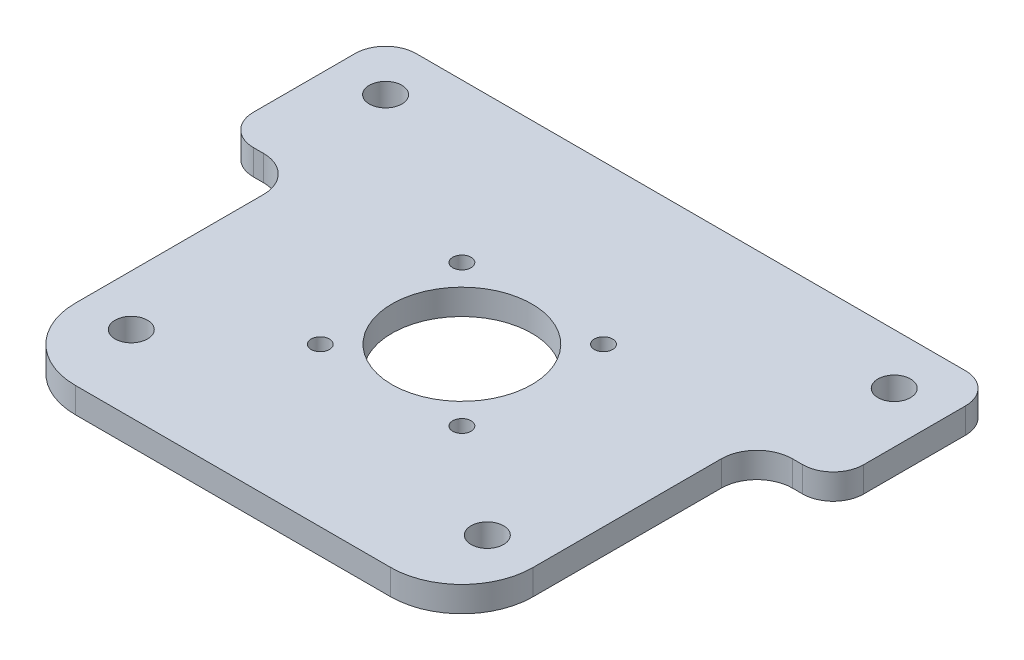
from build123d import *

# Parameters (mm, degrees)
SKETCH1_W           = 114.3
SKETCH1_H           = 114.3
BOSS_EXTRUDE1_DEPTH = 6.35
SKETCH3_W           = 19.05
SKETCH3_H           = 40.64
BOSS_EXTRUDE2_DEPTH = 6.35
SKETCH2_R           = 4.064
SKETCH2_R_2         = 17.4625
SKETCH2_R_3         = 2.286
CUT_EXTRUDE1_DEPTH  = 7.35
FILLET1_R           = 8.89
FILLET2_R           = 17.78
FILLET3_R           = 7.62


with BuildPart() as part:
    # Sketch1 → Boss-Extrude1 (new body)
    with BuildSketch(Plane(origin=(0, 0, 0), x_dir=(1, 0, 0), z_dir=(0, 1, 0))):
        Rectangle(SKETCH1_W, SKETCH1_H)
    extrude(amount=BOSS_EXTRUDE1_DEPTH)

    # Sketch3 → Boss-Extrude2 (add)
    with BuildSketch(Plane(origin=(0, 6.35, 0), x_dir=(1, 0, 0), z_dir=(0, 1, 0))):
        with Locations((66.675, 36.83)):
            Rectangle(SKETCH3_W, SKETCH3_H)
        with Locations((-66.675, 36.83)):
            Rectangle(SKETCH3_W, SKETCH3_H)
    extrude(amount=-BOSS_EXTRUDE2_DEPTH)

    # Sketch2 → Cut-Extrude1 (cut, through all)
    with BuildSketch(Plane(origin=(0, 6.35, 0), x_dir=(1, 0, 0), z_dir=(0, 1, 0))):
        with Locations((-63.5, 44.45)):
            Circle(SKETCH2_R)
        with Locations((63.5, 44.45)):
            Circle(SKETCH2_R)
        with Locations((44.45, -38.1)):
            Circle(SKETCH2_R)
        with Locations((-44.45, -38.1)):
            Circle(SKETCH2_R)
        Circle(SKETCH2_R_2)
        with Locations((-17.67766953, 17.67766953)):
            Circle(SKETCH2_R_3)
        with Locations((17.67766953, 17.67766953)):
            Circle(SKETCH2_R_3)
        with Locations((17.67766953, -17.67766953)):
            Circle(SKETCH2_R_3)
        with Locations((-17.67766953, -17.67766953)):
            Circle(SKETCH2_R_3)
    extrude(amount=-CUT_EXTRUDE1_DEPTH, mode=Mode.SUBTRACT)

    # Fillet1
    fillet1_edges = [part.edges().sort_by_distance(p)[0] for p in [
        (57.15, 3.175, -16.51),
        (-57.15, 3.175, -16.51),
    ]]
    fillet(fillet1_edges, radius=FILLET1_R)

    # Fillet2
    fillet2_edges = [part.edges().sort_by_distance(p)[0] for p in [
        (57.15, 3.175, 57.15),
        (-57.15, 3.175, 57.15),
    ]]
    fillet(fillet2_edges, radius=FILLET2_R)

    # Fillet3
    fillet3_edges = [part.edges().sort_by_distance(p)[0] for p in [
        (76.2, 3.175, -16.51),
        (76.2, 3.175, -57.15),
        (-76.2, 3.175, -57.15),
        (-76.2, 3.175, -16.51),
    ]]
    fillet(fillet3_edges, radius=FILLET3_R)


solid = part.part
